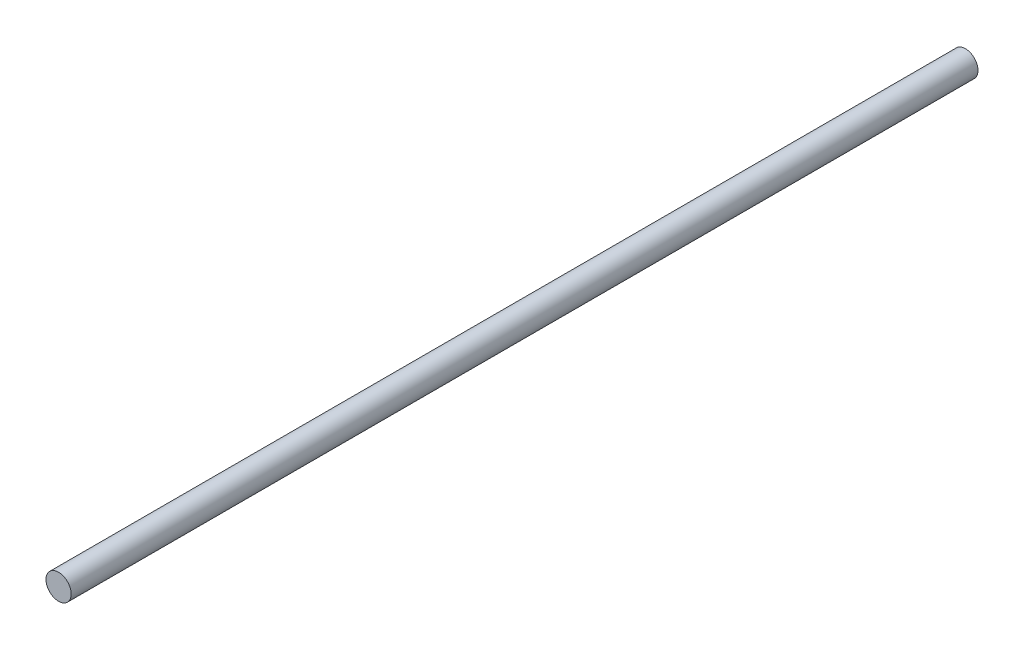
from build123d import *

# Parameters (mm, degrees)
SKETCH1_R           = 2.5
BOSS_EXTRUDE1_DEPTH = 180


with BuildPart() as part:
    # Sketch1 → Boss-Extrude1 (new body)
    with BuildSketch(Plane.XY):
        Circle(SKETCH1_R)
    extrude(amount=BOSS_EXTRUDE1_DEPTH)


solid = part.part
